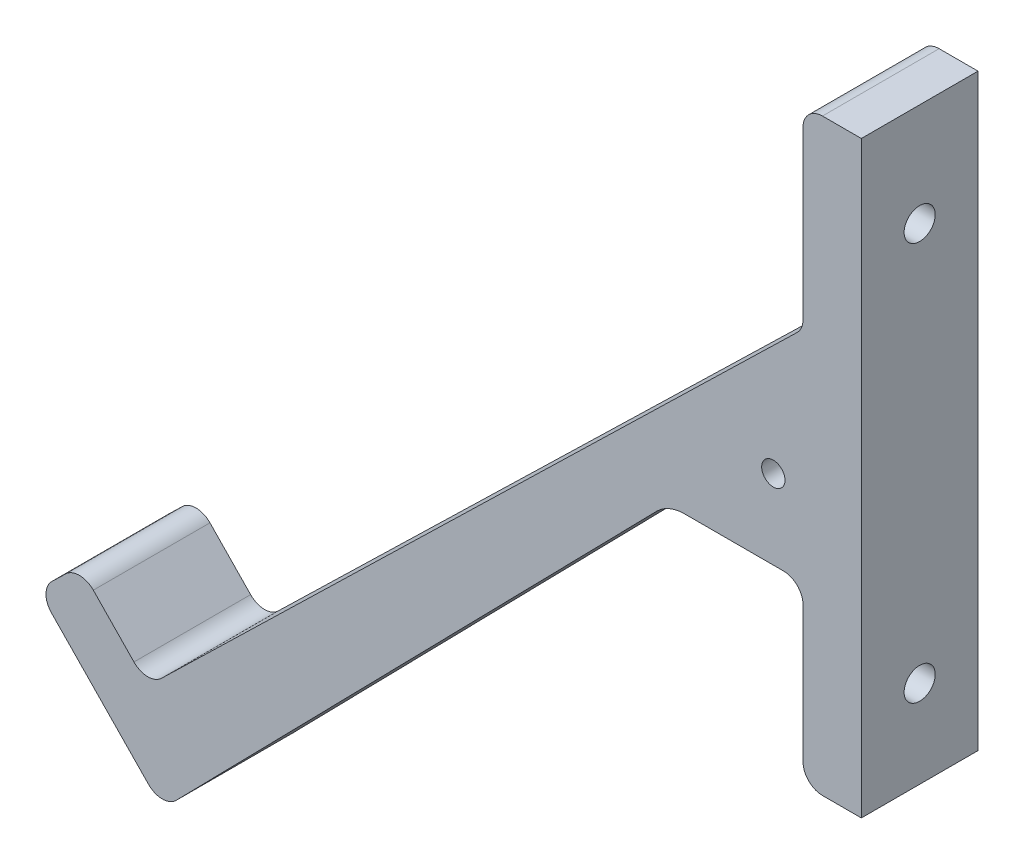
from build123d import *

# Parameters (mm, degrees)
BOSS_EXTRU_3_DEPTH      = 30
ESQUISSE2_W             = 15
ESQUISSE2_H             = 50
BOSS_EXTRU_4_DEPTH      = 30
CONG_1_R                = 5
ESQUISSE3_R             = 4
ENL_V_MAT_EXTRU_1_DEPTH = 30
ESQUISSE4_R             = 4
ENL_V_MAT_EXTRU_2_DEPTH = 30
CONG_2_R                = 0.5
ESQUISSE5_R             = 3
ENL_V_MAT_EXTRU_3_DEPTH = 30


with BuildPart() as part:
    # Esquisse1 → Boss.-Extru.3 (new body)
    with BuildSketch(Plane.XY):
        with BuildLine():
            Line((-1.516636282, -1.472839764), (-164.999487802, -160.23473102))
            ThreePointArc((-164.999487802, -160.23473102), (-168.55609482, -161.647249147), (-172.069796906, -160.131149351))
            Line((-172.069796906, -160.131149351), (-182.523190666, -149.366912378))
            ThreePointArc((-182.523190666, -149.366912378), (-186.036892752, -147.850812582), (-189.593499771, -149.263330708))
            Line((-189.593499771, -149.263330708), (-193.180445158, -152.746694426))
            ThreePointArc((-193.180445158, -152.746694426), (-194.696544953, -156.260396513), (-193.284026827, -159.817003531))
            Line((-193.284026827, -159.817003531), (-179.34726935, -174.168185892))
            Line((-179.34726935, -174.168185892), (-168.352304295, -185.490098382))
            ThreePointArc((-168.352304295, -185.490098382), (-164.775881538, -187.006723591), (-161.193106921, -185.505165132))
            Line((-161.193106921, -185.505165132), (-37.640520995, -59.345455931))
            ThreePointArc((-37.640520995, -59.345455931), (-34.371026094, -57.123623648), (-30.496017021, -56.342316868))
            Line((-30.496017021, -56.342316868), (10, -56.342316868))
            ThreePointArc((10, -56.342316868), (13.535533906, -54.877850774), (15, -51.342316868))
            Line((15, -51.342316868), (15, -6.342316868))
            Line((15, -6.342316868), (15, 50))
            Line((15, 50), (5, 50))
            ThreePointArc((5, 50), (1.464466094, 48.535533906), (0, 45))
            Line((0, 45), (0, 2.114105623))
            ThreePointArc((0, 2.114105623), (-0.394741126, 0.166904887), (-1.516636282, -1.472839764))
        make_face()
    extrude(amount=BOSS_EXTRU_3_DEPTH)

    # Esquisse2 → Boss.-Extru.4 (add)
    with BuildSketch(Plane.XY):
        with Locations((7.5, -76.342316868)):
            Rectangle(ESQUISSE2_W, ESQUISSE2_H)
    extrude(amount=BOSS_EXTRU_4_DEPTH)

    # Congé1
    cong_1_edges = [part.edges().sort_by_distance(p)[0] for p in [
        (0, -56.342316868, 15),
        (0, -101.342316868, 15),
    ]]
    fillet(cong_1_edges, radius=CONG_1_R)

    # Esquisse3 → Enlèv. mat.-Extru.1 (cut)
    with BuildSketch(Plane.ZY):
        with Locations((15, 23.557052811)):
            Circle(ESQUISSE3_R)
    extrude(amount=-ENL_V_MAT_EXTRU_1_DEPTH, mode=Mode.SUBTRACT)

    # Esquisse4 → Enlèv. mat.-Extru.2 (cut)
    with BuildSketch(Plane.ZY):
        with Locations((15, -78.842316868)):
            Circle(ESQUISSE4_R)
    extrude(amount=-ENL_V_MAT_EXTRU_2_DEPTH, mode=Mode.SUBTRACT)

    # Congé2
    cong_2_edges = [part.edges().sort_by_distance(p)[0] for p in [
        (0, 23.557052811, 11),
        (0, -78.842316868, 11),
    ]]
    fillet(cong_2_edges, radius=CONG_2_R)

    # Esquisse5 → Enlèv. mat.-Extru.3 (cut)
    with BuildSketch(Plane.XY.offset(30)):
        with Locations((-7.637173742, -35.95688684)):
            Circle(ESQUISSE5_R)
    extrude(amount=-ENL_V_MAT_EXTRU_3_DEPTH, mode=Mode.SUBTRACT)


solid = part.part
